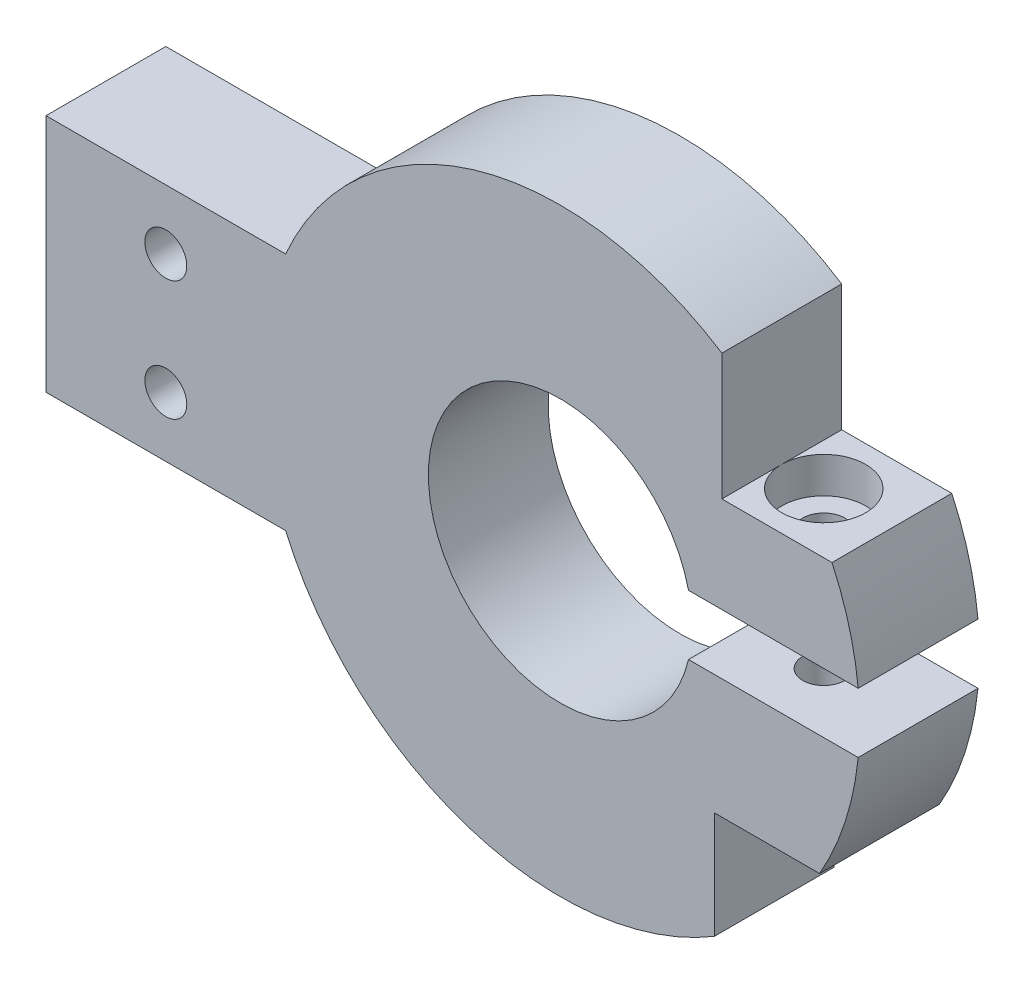
from build123d import *

# Parameters (mm, degrees)
SKETCH1_R                = 25
SKETCH1_R_2              = 11
BOSS_EXTRUDE1_DEPTH      = 10
CUT_EXTRUDE1_DEPTH       = 10
CUT_EXTRUDE4_DEPTH       = 39.487010796
CUT_EXTRUDE4_DEPTH_BACK  = 39.487010796
SKETCH5_R                = 1.75
CUT_EXTRUDE5_START       = 30
SKETCH6_R                = 3.5
CUT_EXTRUDE5_DEPTH       = 20
CUT_EXTRUDE6_START       = -30
CUT_EXTRUDE6_DEPTH       = 25
CUT_EXTRUDE8_START       = 20
CUT_EXTRUDE8_DEPTH       = 15
SKETCH9_W                = 20
SKETCH9_H                = 19.995459106
SKETCH9_R                = 1.75
BOSS_EXTRUDE2_DEPTH      = 10
CUT_EXTRUDE10_DEPTH      = 1
CUT_EXTRUDE10_DEPTH_BACK = 17
CUT_EXTRUDE10_START      = 20
SKETCH13_R               = 3.5
CUT_EXTRUDE11_DEPTH      = 5


with BuildPart() as part:
    # Sketch1 → Boss-Extrude1 (new body)
    with BuildSketch(Plane.XY):
        Circle(SKETCH1_R)
        Circle(SKETCH1_R_2, mode=Mode.SUBTRACT)
    extrude(amount=BOSS_EXTRUDE1_DEPTH)

    # Sketch2 → Cut-Extrude1 (cut)
    with BuildSketch(Plane.XY.offset(10)):
        Polygon((25, 0), (25, 2.5), (0, 2.5), (0, 0), (0, -2.5), (25, -2.5), align=None)
    extrude(amount=-CUT_EXTRUDE1_DEPTH, mode=Mode.SUBTRACT)

    # Sketch5 → Cut-Extrude4 (cut, two sides: drawn at the far end of the back side and taken through both)
    with BuildSketch(Plane(origin=(0, -2.5, 0), x_dir=(1, 0, 0), z_dir=(0, 1, 0)).offset(-CUT_EXTRUDE4_DEPTH_BACK)):
        with Locations((17, -5)):
            Circle(SKETCH5_R)
    extrude(amount=CUT_EXTRUDE4_DEPTH + CUT_EXTRUDE4_DEPTH_BACK, mode=Mode.SUBTRACT)

    # Sketch6 → Cut-Extrude5 (cut)
    with BuildSketch(Plane(origin=(0, -2.5, 0), x_dir=(1, 0, 0), z_dir=(0, 1, 0)).offset(CUT_EXTRUDE5_START)):
        with Locations((17, -5)):
            Circle(SKETCH6_R)
    extrude(amount=-CUT_EXTRUDE5_DEPTH, mode=Mode.SUBTRACT)

    # Sketch7 → Cut-Extrude6 (cut)
    with BuildSketch(Plane(origin=(0, -2.5, 0), x_dir=(1, 0, 0), z_dir=(0, 1, 0)).offset(CUT_EXTRUDE6_START)):
        Polygon((21.041451884, -5), (19.020725942, -1.5), (14.979274058, -1.5), (12.958548116, -5), (14.979274058, -8.5), (19.020725942, -8.5), align=None)
    extrude(amount=CUT_EXTRUDE6_DEPTH, mode=Mode.SUBTRACT)

    # Sketch8 → Cut-Extrude8 (cut)
    with BuildSketch(Plane.XZ.offset(7.5).offset(CUT_EXTRUDE8_START)):
        Polygon((12.866790083, 5), (12.866790083, -1.917841475), (27.200285801, -1.917841475), (26.866413077, 13.440303847), (13.08223917, 14.012657089), (12.866790083, 14.617290025), align=None)
    extrude(amount=-CUT_EXTRUDE8_DEPTH, mode=Mode.SUBTRACT)

    # Sketch9 → Boss-Extrude2 (add)
    with BuildSketch(Plane(origin=(0, 0, 0), x_dir=(-1, 0, 0), z_dir=(0, 0, -1))):
        with Locations((32.913869245, 0)):
            Rectangle(SKETCH9_W, SKETCH9_H)
        with Locations((32.913869245, 5)):
            Circle(SKETCH9_R, mode=Mode.SUBTRACT)
        with Locations((32.913869245, -5)):
            Circle(SKETCH9_R, mode=Mode.SUBTRACT)
    extrude(amount=-BOSS_EXTRUDE2_DEPTH)

    # Sketch12 → Cut-Extrude10 (cut, two sides: drawn at the far end of the back side and taken through both)
    with BuildSketch(Plane(origin=(0, 7.5, 0), x_dir=(1, 0, 0), z_dir=(0, 1, 0)).offset(CUT_EXTRUDE10_START - CUT_EXTRUDE10_DEPTH_BACK)):
        Polygon((13.5, -5), (13.5, -13.927186896), (27.549462707, -13.927186896), (27.549462707, 2.179730433), (13.5, 2.179730433), align=None)
    extrude(amount=CUT_EXTRUDE10_DEPTH + CUT_EXTRUDE10_DEPTH_BACK, mode=Mode.SUBTRACT)

    # Sketch13 → Cut-Extrude11 (cut)
    with BuildSketch(Plane(origin=(0, 0, 0), x_dir=(-1, 0, 0), z_dir=(0, 0, -1))):
        with Locations((32.913869245, 5)):
            Circle(SKETCH13_R)
        with Locations((32.913869245, -5)):
            Circle(SKETCH13_R)
    extrude(amount=-CUT_EXTRUDE11_DEPTH, mode=Mode.SUBTRACT)


solid = part.part
